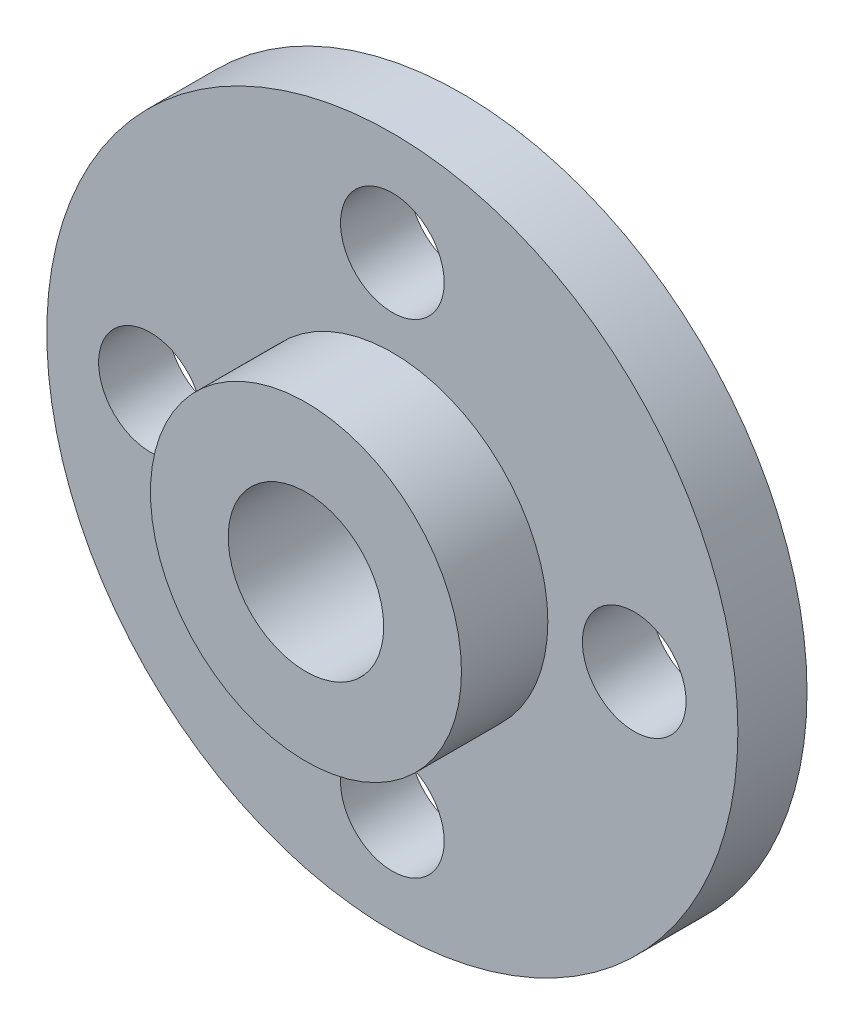
from build123d import *

# Parameters (mm, degrees)
SKETCH_1_R      = 10
SKETCH_1_R_2    = 2.25
SKETCH_1_R_3    = 1.5
EXTRUDE_1_DEPTH = 2
SKETCH_2_R      = 4.5
SKETCH_2_R_2    = 2.25
EXTRUDE_2_DEPTH = 2.5


with BuildPart() as part:
    # 草图1 → 凸台-拉伸1 (new body)
    with BuildSketch(Plane.XY):
        Circle(SKETCH_1_R)
        Circle(SKETCH_1_R_2, mode=Mode.SUBTRACT)
        with Locations((7, 0)):
            Circle(SKETCH_1_R_3, mode=Mode.SUBTRACT)
        with Locations((0, -7)):
            Circle(SKETCH_1_R_3, mode=Mode.SUBTRACT)
        with Locations((-7, 0)):
            Circle(SKETCH_1_R_3, mode=Mode.SUBTRACT)
        with Locations((0, 7)):
            Circle(SKETCH_1_R_3, mode=Mode.SUBTRACT)
    extrude(amount=EXTRUDE_1_DEPTH)

    # 草图2 → 凸台-拉伸2 (add)
    with BuildSketch(Plane.XY.offset(2)):
        Circle(SKETCH_2_R)
        Circle(SKETCH_2_R_2, mode=Mode.SUBTRACT)
    extrude(amount=EXTRUDE_2_DEPTH)


solid = part.part
